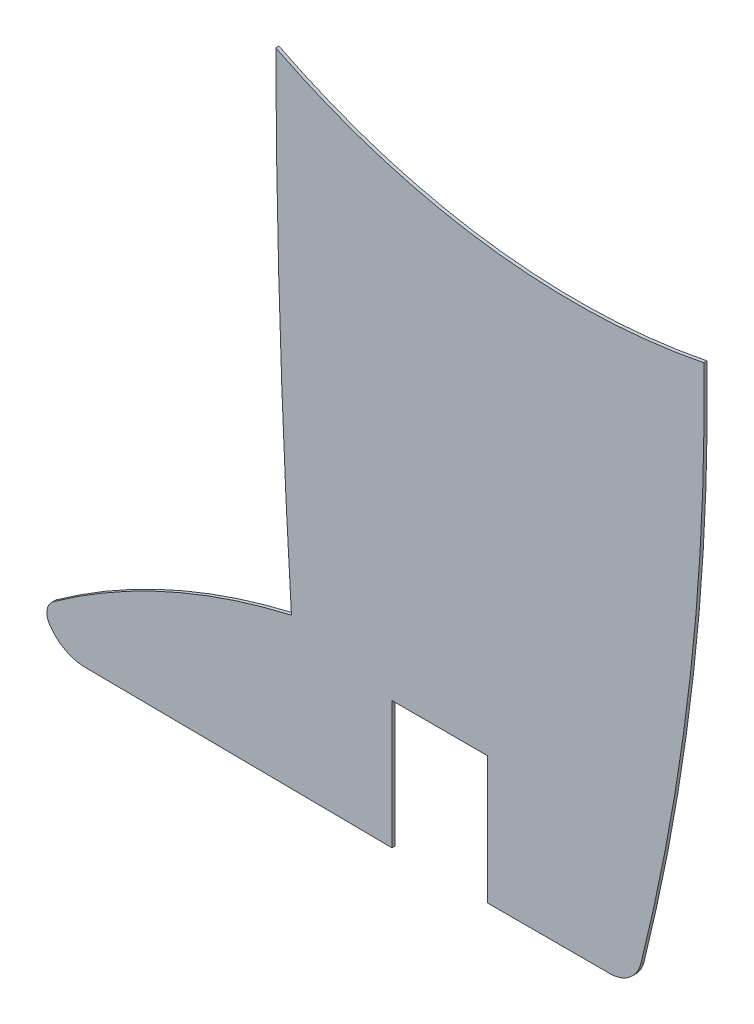
from build123d import *

# Parameters (mm, degrees)
SALIENTE_EXTRUIR1_DEPTH = 0.1


with BuildPart() as part:
    # Model → Saliente-Extruir1 (new body)
    with BuildSketch(Plane.XY):
        with BuildLine():
            Line((27.419125066, -46.711901605), (17.855705746, -46.621328457))
            ThreePointArc((17.855705746, -46.621328457), (17.185424798, -46.47100647), (16.673913765, -46.012498333))
            ThreePointArc((16.673913765, -46.012498333), (16.598467504, -45.649222161), (16.794123037, -45.333975231))
            ThreePointArc((16.794123037, -45.333975231), (20.362195737, -43.279741776), (24.264393991, -41.966780746))
            ThreePointArc((24.264393991, -41.966780746), (23.908199582, -34.385858307), (23.772490147, -26.797785927))
            ThreePointArc((23.772490147, -26.797785927), (30.332057529, -28.845679283), (37.200740842, -28.638360736))
            ThreePointArc((37.200740842, -28.638360736), (36.777649791, -37.362977687), (35.226615012, -45.959037138))
            ThreePointArc((35.226615012, -45.959037138), (34.871092661, -46.500894758), (34.258012391, -46.710986181))
            Line((34.258012391, -46.710986181), (30.419140985, -46.711540389))
            Line((30.419140985, -46.711540389), (30.419140797, -42.710240543))
            Line((30.419140797, -42.710240543), (27.419140797, -42.710240543))
            Line((27.419140797, -42.710240543), (27.419125066, -46.711901605))
        make_face()
    extrude(amount=SALIENTE_EXTRUIR1_DEPTH)


solid = part.part
